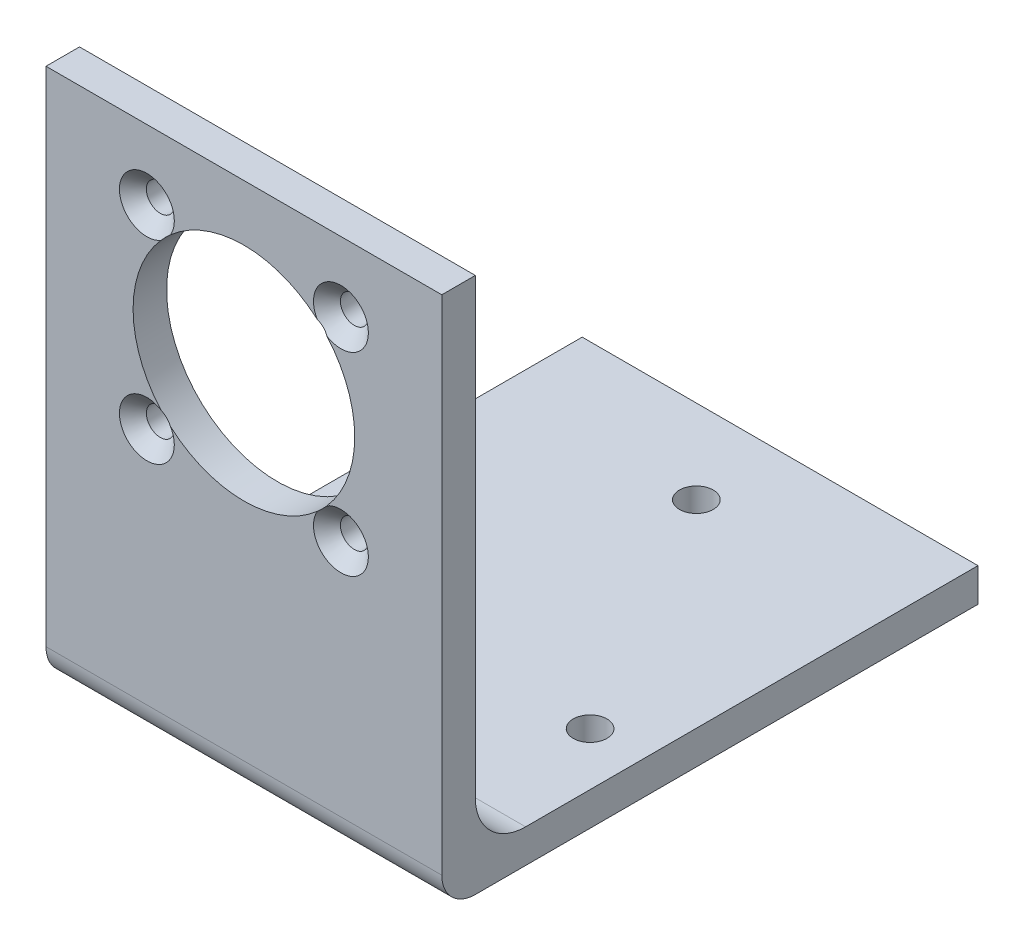
from build123d import *

# Parameters (mm, degrees)
BOSS_EXTRUDE1_DEPTH  = 75
FILLET1_R            = 6.35
SKETCH2_R            = 21
CUT_EXTRUDE1_DEPTH   = 75
CIRPATTERN1_COUNT    = 4
M6_CLEARANCE_HOLE1_D = 6.4


with BuildPart() as part:
    # Sketch1 → Boss-Extrude1 (new body)
    with BuildSketch(Plane(origin=(0, 0, 0), x_dir=(0, 0, -1), z_dir=(1, 0, 0))):
        with BuildLine():
            Line((0, 0), (0, 101.6))
            Line((0, 101.6), (6.35, 101.6))
            Line((6.35, 101.6), (6.35, 15.875))
            ThreePointArc((6.35, 15.875), (9.139807909, 9.139807909), (15.875, 6.35))
            Line((15.875, 6.35), (101.6, 6.35))
            Line((101.6, 6.35), (101.6, 0))
            Line((101.6, 0), (0, 0))
        make_face()
    extrude(amount=BOSS_EXTRUDE1_DEPTH)

    # Fillet1
    fillet1_edges = [part.edges().sort_by_distance(p)[0] for p in [
        (37.5, 0, 0),
    ]]
    fillet(fillet1_edges, radius=FILLET1_R)

    # Sketch2 → Cut-Extrude1 (cut)
    with BuildSketch(Plane(origin=(0, 0, 0), x_dir=(-1, 0, 0), z_dir=(0, 0, -1))):
        with Locations((-37.5, 70)):
            Circle(SKETCH2_R)
    extrude(amount=CUT_EXTRUDE1_DEPTH, mode=Mode.SUBTRACT)

    # Sketch13 → CSK for M5 Flat Head Machine Screw3 (revolve, cut)
    with BuildSketch(Plane(origin=(55.884776311, 88.384776311, 0), x_dir=(0, -1, 0), z_dir=(1, 0, 0))):
        Polygon((0, 0), (0, 14.29228064), (2.65, 12.7), (2.65, 2.55), (5.2, 0), align=None)
    csk_for_m5_flat_head_machine_screw3 = revolve(axis=Axis((55.884776311, 88.384776311, 6.35), (0, 0, -1)), mode=Mode.SUBTRACT)

    # CirPattern1: CSK for M5 Flat Head Machine Screw3 ×4 about axis
    cirpattern1_axis = Axis((37.5, 70, -75), (0, 0, 1))
    for i in range(1, CIRPATTERN1_COUNT):
        add(csk_for_m5_flat_head_machine_screw3.rotate(cirpattern1_axis, i * 360 / CIRPATTERN1_COUNT), mode=Mode.SUBTRACT)

    # M6 Clearance Hole1 (through all)
    with Locations(Plane(origin=(37.5, 6.35, -85.729264805), x_dir=(0, 0, 1), z_dir=(0, 1, 0))):
        with Locations((0, 0), (47.631397208, 27.5), (47.631397208, -27.5)):
            Hole(M6_CLEARANCE_HOLE1_D / 2)


solid = part.part
